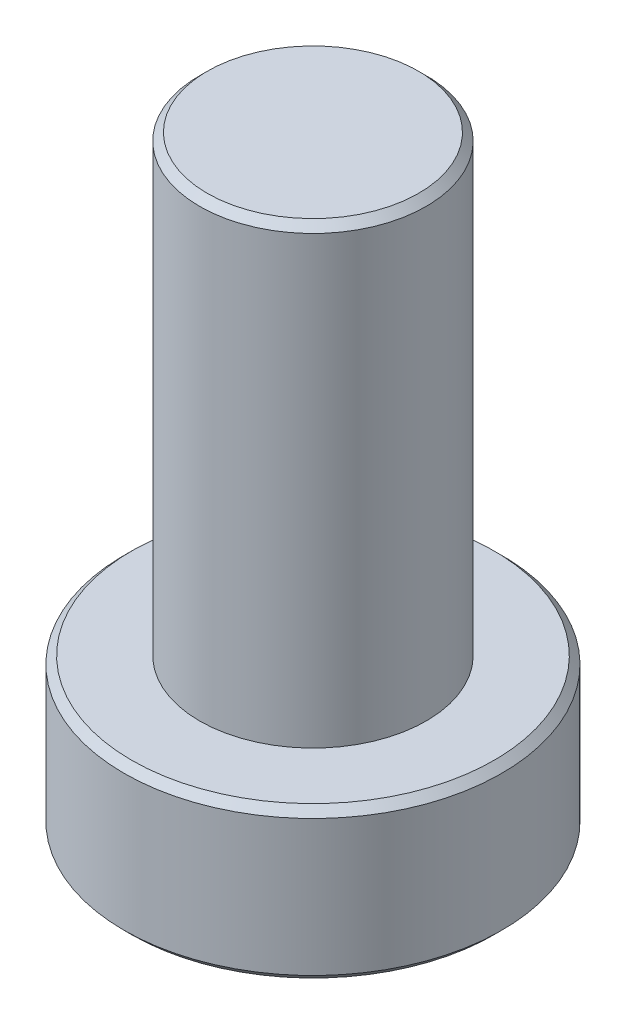
from build123d import *

# Parameters (mm, degrees)
SKETCH_1_R      = 5
EXTRUDE_1_DEPTH = 4
SKETCH_2_R      = 3
EXTRUDE_2_DEPTH = 12
CHAMFER_1_SIZE  = 0.2


with BuildPart() as part:
    # Эскиз1 → Бобышка-Вытянуть1 (new body)
    with BuildSketch(Plane(origin=(0, 0, 0), x_dir=(1, 0, 0), z_dir=(0, 1, 0))):
        Circle(SKETCH_1_R)
    extrude(amount=EXTRUDE_1_DEPTH)

    # Эскиз2 → Бобышка-Вытянуть2 (add)
    with BuildSketch(Plane(origin=(0, 4, 0), x_dir=(1, 0, 0), z_dir=(0, 1, 0))):
        Circle(SKETCH_2_R)
    extrude(amount=EXTRUDE_2_DEPTH)

    # Фаска1
    chamfer_1_edges = [part.edges().sort_by_distance(p)[0] for p in [
        (-5, 0, 0),
        (-5, 4, 0),
        (-3, 16, 0),
    ]]
    chamfer(chamfer_1_edges, length=CHAMFER_1_SIZE)


solid = part.part
